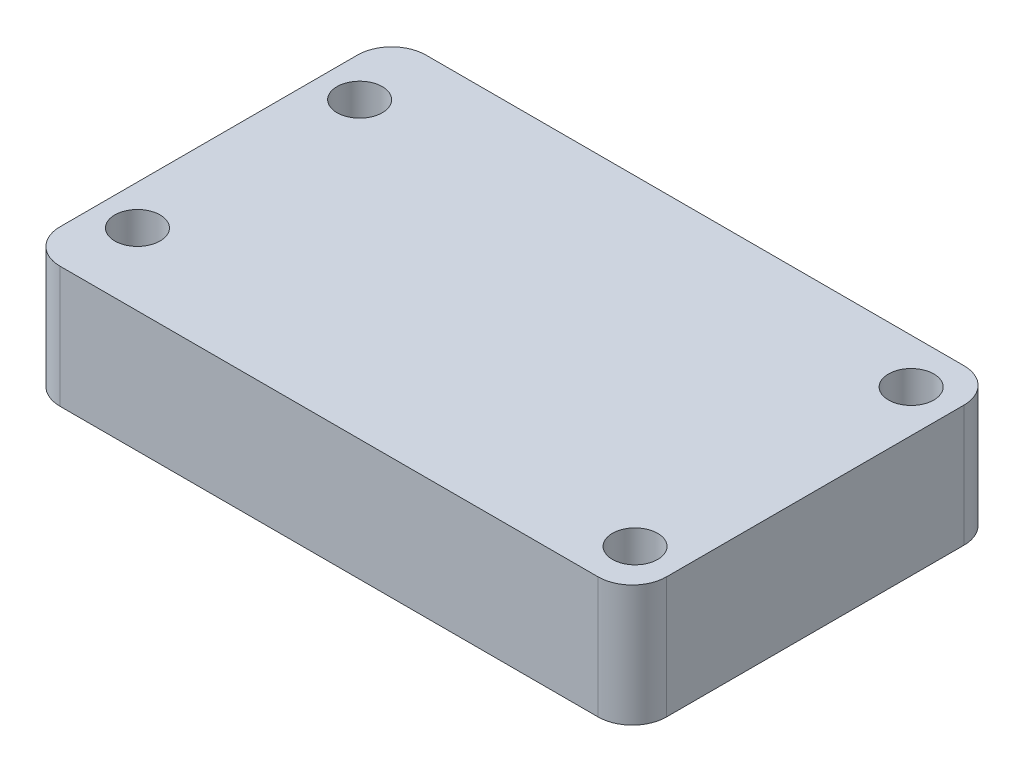
from build123d import *

# Parameters (mm, degrees)
SKETCH1_W           = 36.0426
SKETCH1_H           = 21.7424
BOSS_EXTRUDE1_DEPTH = 7.2136
SKETCH2_R           = 1.3462
CUT_EXTRUDE1_DEPTH  = 7.2136
FILLET1_R           = 2.032


with BuildPart() as part:
    # Sketch1 → Boss-Extrude1 (new body)
    with BuildSketch(Plane(origin=(0, 0, 0), x_dir=(1, 0, 0), z_dir=(0, 1, 0))):
        with Locations((-73.427135669, 1.514506775)):
            Rectangle(SKETCH1_W, SKETCH1_H)
    extrude(amount=BOSS_EXTRUDE1_DEPTH)

    # Sketch2 → Cut-Extrude1 (cut)
    with BuildSketch(Plane(origin=(0, 7.2136, 0), x_dir=(1, 0, 0), z_dir=(0, 1, 0))):
        with Locations((-57.907735669, 9.718706775)):
            Circle(SKETCH2_R)
        with Locations((-89.086235669, 8.118506775)):
            Circle(SKETCH2_R)
        with Locations((-57.907735669, -6.689693225)):
            Circle(SKETCH2_R)
        with Locations((-89.086235669, -5.089493225)):
            Circle(SKETCH2_R)
    extrude(amount=-CUT_EXTRUDE1_DEPTH, mode=Mode.SUBTRACT)

    # Fillet1
    fillet1_edges = [part.edges().sort_by_distance(p)[0] for p in [
        (-91.448435669, 3.6068, -12.385706775),
        (-55.405835669, 3.6068, -12.385706775),
        (-55.405835669, 3.6068, 9.356693225),
        (-91.448435669, 3.6068, 9.356693225),
    ]]
    fillet(fillet1_edges, radius=FILLET1_R)


solid = part.part
